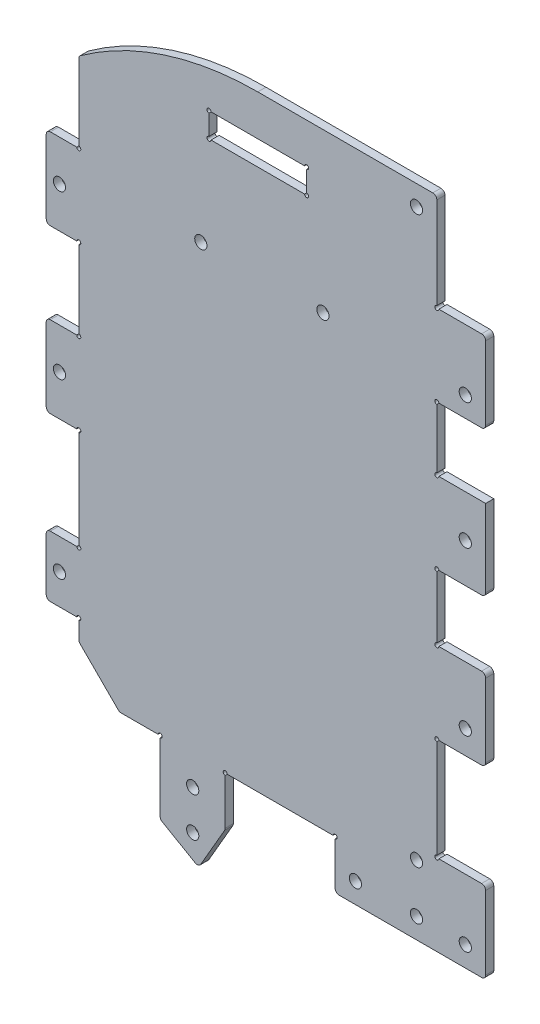
from build123d import *

# Parameters (mm, degrees)
SKETCH_1_R          = 1.5
EXTRUDE_2_DEPTH     = 2
SKETCH_2_R          = 1.5
CUT_EXTRUDE_1_DEPTH = 10
SKETCH_3_R          = 0.5
CUT_EXTRUDE_2_DEPTH = 3
FILLET_1_R          = 1
SKETCH_4_R          = 0.5
SKETCH_4_W          = 24
SKETCH_4_H          = 6
CUT_EXTRUDE_3_DEPTH = 3


with BuildPart() as part:
    # 草图1 → 凸台-拉伸2 (new body)
    with BuildSketch(Plane.XY):
        with BuildLine():
            Line((56, -66.5), (44, -66.5))
            Line((44, -66.5), (44, -41.3))
            Line((44, -41.3), (56, -41.3))
            Line((56, -41.3), (56, -21.3))
            Line((56, -21.3), (44, -21.3))
            Line((44, -21.3), (44, -5.1))
            Line((44, -5.1), (56, -5.1))
            Line((56, -5.1), (56, 14.9))
            Line((56, 14.9), (44, 14.9))
            Line((44, 14.9), (44, 30.5))
            Line((44, 30.5), (56, 30.5))
            Line((56, 30.5), (56, 50.5))
            Line((56, 50.5), (44, 50.5))
            Line((44, 50.5), (44, 74.5))
            Line((44, 74.5), (0, 74.5))
            ThreePointArc((0, 74.5), (-23.145322016, 70.813445537), (-44, 60.118632719))
            Line((-44, 60.118632719), (-44, 40.5))
            Line((-44, 40.5), (-52, 40.5))
            Line((-52, 40.5), (-52, 20.5))
            Line((-52, 20.5), (-44, 20.5))
            Line((-44, 20.5), (-44, 0.5))
            Line((-44, 0.5), (-52, 0.5))
            Line((-52, 0.5), (-52, -19.5))
            Line((-52, -19.5), (-44, -19.5))
            Line((-44, -19.5), (-44, -44.5))
            Line((-44, -44.5), (-52, -44.5))
            Line((-52, -44.5), (-52, -59.5))
            Line((-52, -59.5), (-44, -59.5))
            Line((-44, -59.5), (-44, -64.5))
            Line((-44, -64.5), (-34, -74.5))
            Line((-34, -74.5), (-24, -74.5))
            Line((-24, -74.5), (-24, -92.324700538))
            Line((-24, -92.324700538), (-14.522169318, -97.796728634))
            Line((-14.522169318, -97.796728634), (-8, -86.5))
            Line((-8, -86.5), (-8, -74.5))
            Line((-8, -74.5), (19, -74.5))
            Line((19, -74.5), (19, -86.5))
            Line((19, -86.5), (56, -86.5))
            Line((56, -86.5), (56, -66.5))
        make_face()
        with Locations((24, -81.5)):
            Circle(SKETCH_1_R, mode=Mode.SUBTRACT)
        with Locations((39, -81.5)):
            Circle(SKETCH_1_R, mode=Mode.SUBTRACT)
        with Locations((51, -81.5)):
            Circle(SKETCH_1_R, mode=Mode.SUBTRACT)
        with Locations((16, 35.5)):
            Circle(SKETCH_1_R, mode=Mode.SUBTRACT)
        with Locations((39, 69.5)):
            Circle(SKETCH_1_R, mode=Mode.SUBTRACT)
        with Locations((39, -69.5)):
            Circle(SKETCH_1_R, mode=Mode.SUBTRACT)
        with Locations((-14, 35.5)):
            Circle(SKETCH_1_R, mode=Mode.SUBTRACT)
        with Locations((-16, -81.5)):
            Circle(SKETCH_1_R, mode=Mode.SUBTRACT)
        with Locations((-16, -91.17)):
            Circle(SKETCH_1_R, mode=Mode.SUBTRACT)
        with Locations((51, -35.5)):
            Circle(SKETCH_1_R, mode=Mode.SUBTRACT)
        with Locations((51, 4.5)):
            Circle(SKETCH_1_R, mode=Mode.SUBTRACT)
        with Locations((51, 35.5)):
            Circle(SKETCH_1_R, mode=Mode.SUBTRACT)
    extrude(amount=EXTRUDE_2_DEPTH)

    # 草图2 → 切除-拉伸1 (cut)
    with BuildSketch(Plane(origin=(0, 0, 0), x_dir=(-1, 0, 0), z_dir=(0, 0, -1))):
        with Locations((48.75, 30.5)):
            Circle(SKETCH_2_R)
        with Locations((48.75, -9.5)):
            Circle(SKETCH_2_R)
        with Locations((48.75, -52)):
            Circle(SKETCH_2_R)
    extrude(amount=-CUT_EXTRUDE_1_DEPTH, mode=Mode.SUBTRACT)

    # 草图3 → 切除-拉伸2 (cut, through all)
    with BuildSketch(Plane(origin=(0, 0, 0), x_dir=(-1, 0, 0), z_dir=(0, 0, -1))):
        with Locations((-44, 50.5)):
            Circle(SKETCH_3_R)
        with Locations((-44, 30.5)):
            Circle(SKETCH_3_R)
        with Locations((-44, 14.9)):
            Circle(SKETCH_3_R)
        with Locations((-44, -5.1)):
            Circle(SKETCH_3_R)
        with Locations((-44, -21.3)):
            Circle(SKETCH_3_R)
        with Locations((-44, -41.3)):
            Circle(SKETCH_3_R)
        with Locations((-44, -66.5)):
            Circle(SKETCH_3_R)
        with Locations((44, 40.5)):
            Circle(SKETCH_3_R)
        with Locations((44, 20.5)):
            Circle(SKETCH_3_R)
        with Locations((44, 0.5)):
            Circle(SKETCH_3_R)
        with Locations((44, -19.5)):
            Circle(SKETCH_3_R)
        with Locations((44, -44.5)):
            Circle(SKETCH_3_R)
        with Locations((44, -59.5)):
            Circle(SKETCH_3_R)
        with Locations((-19, -74.5)):
            Circle(SKETCH_3_R)
        with Locations((8, -74.5)):
            Circle(SKETCH_3_R)
        with Locations((24, -74.5)):
            Circle(SKETCH_3_R)
    extrude(amount=-CUT_EXTRUDE_2_DEPTH, mode=Mode.SUBTRACT)

    # 圆角1
    fillet_1_edges = [part.edges().sort_by_distance(p)[0] for p in [
        (-8, -86.5, 1),
        (-14.522169318, -97.796728634, 1),
        (-24, -92.324700538, 1),
        (-34, -74.5, 1),
        (-44, -64.5, 1),
        (-52, -59.5, 1),
        (-52, -44.5, 1),
        (-52, -19.5, 1),
        (-52, 0.5, 1),
        (-52, 20.5, 1),
        (-52, 40.5, 1),
        (-44, 60.118632719, 1),
        (44, 74.5, 1),
        (56, 50.5, 1),
        (56, 30.5, 1),
        (56, -5.1, 1),
        (56, -21.3, 1),
        (56, -41.3, 1),
        (56, -66.5, 1),
        (56, -86.5, 1),
        (19, -86.5, 1),
    ]]
    fillet(fillet_1_edges, radius=FILLET_1_R)

    # 草图4 → 切除-拉伸3 (cut, through all)
    with BuildSketch(Plane(origin=(0, 0, 0), x_dir=(-1, 0, 0), z_dir=(0, 0, -1))):
        with BuildLine():
            Line((-12, 64), (-12, 64.5))
            Line((-12, 64.5), (-11.5, 64.5))
            ThreePointArc((-11.5, 64.5), (-12.353553391, 64.853553391), (-12, 64))
        make_face()
        with BuildLine():
            Line((-11.5, 64.5), (-12, 64.5))
            Line((-12, 64.5), (-12, 64))
            ThreePointArc((-12, 64), (-11.646446609, 64.146446609), (-11.5, 64.5))
        make_face()
        with BuildLine():
            ThreePointArc((-11.5, 58.5), (-11.646446609, 58.853553391), (-12, 59))
            Line((-12, 59), (-12, 58.5))
            Line((-12, 58.5), (-11.5, 58.5))
        make_face()
        with BuildLine():
            Line((-12, 58.5), (-12, 59))
            ThreePointArc((-12, 59), (-12.353553391, 58.146446609), (-11.5, 58.5))
            Line((-11.5, 58.5), (-12, 58.5))
        make_face()
        with Locations((12, 58.5)):
            Circle(SKETCH_4_R)
        with Locations((12, 64.5)):
            Circle(SKETCH_4_R)
        with Locations((-12, 64.5)):
            Circle(SKETCH_4_R)
        with Locations((-12, 58.5)):
            Circle(SKETCH_4_R)
        with Locations((0, 61.5)):
            Rectangle(SKETCH_4_W, SKETCH_4_H)
        with BuildLine():
            ThreePointArc((12.5, 64.5), (12, 65), (11.5, 64.5))
            Line((11.5, 64.5), (12, 64.5))
            Line((12, 64.5), (12, 64))
            ThreePointArc((12, 64), (12.353553391, 64.146446609), (12.5, 64.5))
        make_face()
        with BuildLine():
            Line((12, 64.5), (11.5, 64.5))
            ThreePointArc((11.5, 64.5), (11.646446609, 64.146446609), (12, 64))
            Line((12, 64), (12, 64.5))
        make_face()
        with BuildLine():
            ThreePointArc((12.5, 58.5), (12.353553391, 58.853553391), (12, 59))
            Line((12, 59), (12, 58.5))
            Line((12, 58.5), (11.5, 58.5))
            ThreePointArc((11.5, 58.5), (12, 58), (12.5, 58.5))
        make_face()
        with BuildLine():
            Line((12, 58.5), (12, 59))
            ThreePointArc((12, 59), (11.646446609, 58.853553391), (11.5, 58.5))
            Line((11.5, 58.5), (12, 58.5))
        make_face()
    extrude(amount=-CUT_EXTRUDE_3_DEPTH, mode=Mode.SUBTRACT)


solid = part.part
